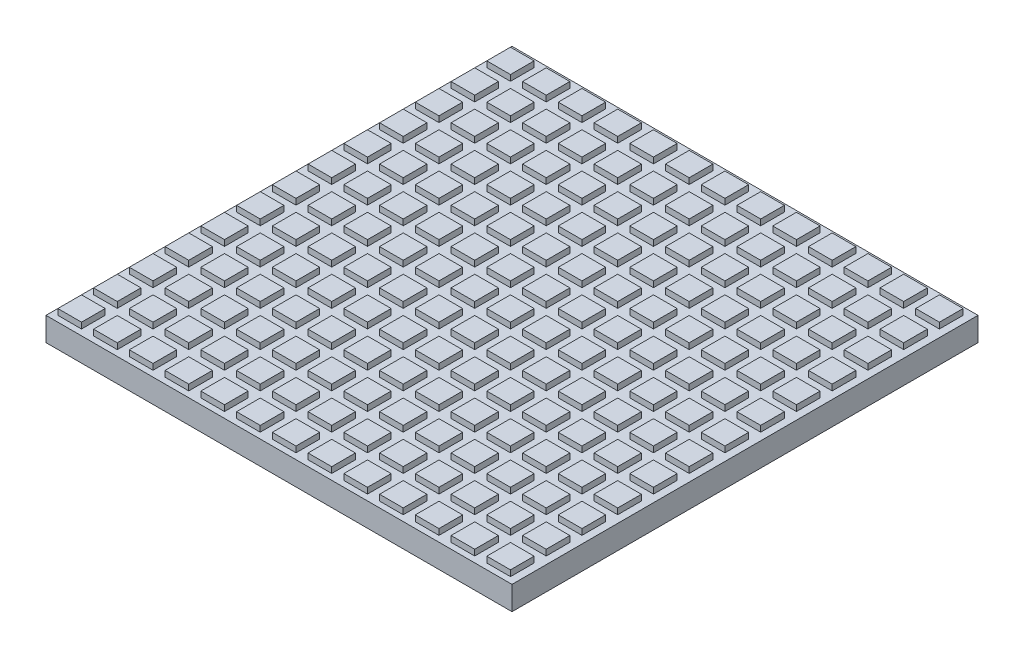
from build123d import *

# Parameters (mm, degrees)
SKETCH1_W           = 500
SKETCH1_H           = 500
BOSS_EXTRUDE1_DEPTH = 25.4
SKETCH2_W           = 25.4
SKETCH2_H           = 25.4
BOSS_EXTRUDE2_DEPTH = 6.35


with BuildPart() as part:
    # Sketch1 → Boss-Extrude1 (new body)
    with BuildSketch(Plane(origin=(0, 0, 0), x_dir=(1, 0, 0), z_dir=(0, 1, 0))):
        Rectangle(SKETCH1_W, SKETCH1_H)
    extrude(amount=BOSS_EXTRUDE1_DEPTH)

    # Sketch2 → Boss-Extrude2 (add)
    with BuildSketch(Plane(origin=(0, 25.4, 0), x_dir=(1, 0, 0), z_dir=(0, 1, 0))):
        with Locations((-230.95, -230.95)):
            Rectangle(SKETCH2_W, SKETCH2_H)
        with Locations((-192.596, -230.95)):
            Rectangle(SKETCH2_W, SKETCH2_H)
        with Locations((-154.242, -230.95)):
            Rectangle(SKETCH2_W, SKETCH2_H)
        with Locations((-115.888, -230.95)):
            Rectangle(SKETCH2_W, SKETCH2_H)
        with Locations((-77.534, -230.95)):
            Rectangle(SKETCH2_W, SKETCH2_H)
        with Locations((-39.18, -230.95)):
            Rectangle(SKETCH2_W, SKETCH2_H)
        with Locations((-0.826, -230.95)):
            Rectangle(SKETCH2_W, SKETCH2_H)
        with Locations((37.528, -230.95)):
            Rectangle(SKETCH2_W, SKETCH2_H)
        with Locations((75.882, -230.95)):
            Rectangle(SKETCH2_W, SKETCH2_H)
        with Locations((114.236, -230.95)):
            Rectangle(SKETCH2_W, SKETCH2_H)
        with Locations((152.59, -230.95)):
            Rectangle(SKETCH2_W, SKETCH2_H)
        with Locations((190.944, -230.95)):
            Rectangle(SKETCH2_W, SKETCH2_H)
        with Locations((229.298, -230.95)):
            Rectangle(SKETCH2_W, SKETCH2_H)
        with Locations((-192.596, -192.596)):
            Rectangle(SKETCH2_W, SKETCH2_H)
        with Locations((-154.242, -192.596)):
            Rectangle(SKETCH2_W, SKETCH2_H)
        with Locations((-115.888, -192.596)):
            Rectangle(SKETCH2_W, SKETCH2_H)
        with Locations((-77.534, -192.596)):
            Rectangle(SKETCH2_W, SKETCH2_H)
        with Locations((-39.18, -192.596)):
            Rectangle(SKETCH2_W, SKETCH2_H)
        with Locations((-0.826, -192.596)):
            Rectangle(SKETCH2_W, SKETCH2_H)
        with Locations((37.528, -192.596)):
            Rectangle(SKETCH2_W, SKETCH2_H)
        with Locations((75.882, -192.596)):
            Rectangle(SKETCH2_W, SKETCH2_H)
        with Locations((114.236, -192.596)):
            Rectangle(SKETCH2_W, SKETCH2_H)
        with Locations((152.59, -192.596)):
            Rectangle(SKETCH2_W, SKETCH2_H)
        with Locations((190.944, -192.596)):
            Rectangle(SKETCH2_W, SKETCH2_H)
        with Locations((229.298, -192.596)):
            Rectangle(SKETCH2_W, SKETCH2_H)
        with Locations((-192.596, -154.242)):
            Rectangle(SKETCH2_W, SKETCH2_H)
        with Locations((-154.242, -154.242)):
            Rectangle(SKETCH2_W, SKETCH2_H)
        with Locations((-115.888, -154.242)):
            Rectangle(SKETCH2_W, SKETCH2_H)
        with Locations((-77.534, -154.242)):
            Rectangle(SKETCH2_W, SKETCH2_H)
        with Locations((-39.18, -154.242)):
            Rectangle(SKETCH2_W, SKETCH2_H)
        with Locations((-0.826, -154.242)):
            Rectangle(SKETCH2_W, SKETCH2_H)
        with Locations((37.528, -154.242)):
            Rectangle(SKETCH2_W, SKETCH2_H)
        with Locations((75.882, -154.242)):
            Rectangle(SKETCH2_W, SKETCH2_H)
        with Locations((114.236, -154.242)):
            Rectangle(SKETCH2_W, SKETCH2_H)
        with Locations((152.59, -154.242)):
            Rectangle(SKETCH2_W, SKETCH2_H)
        with Locations((190.944, -154.242)):
            Rectangle(SKETCH2_W, SKETCH2_H)
        with Locations((229.298, -154.242)):
            Rectangle(SKETCH2_W, SKETCH2_H)
        with Locations((-192.596, -115.888)):
            Rectangle(SKETCH2_W, SKETCH2_H)
        with Locations((-154.242, -115.888)):
            Rectangle(SKETCH2_W, SKETCH2_H)
        with Locations((-115.888, -115.888)):
            Rectangle(SKETCH2_W, SKETCH2_H)
        with Locations((-77.534, -115.888)):
            Rectangle(SKETCH2_W, SKETCH2_H)
        with Locations((-39.18, -115.888)):
            Rectangle(SKETCH2_W, SKETCH2_H)
        with Locations((-0.826, -115.888)):
            Rectangle(SKETCH2_W, SKETCH2_H)
        with Locations((37.528, -115.888)):
            Rectangle(SKETCH2_W, SKETCH2_H)
        with Locations((75.882, -115.888)):
            Rectangle(SKETCH2_W, SKETCH2_H)
        with Locations((114.236, -115.888)):
            Rectangle(SKETCH2_W, SKETCH2_H)
        with Locations((152.59, -115.888)):
            Rectangle(SKETCH2_W, SKETCH2_H)
        with Locations((190.944, -115.888)):
            Rectangle(SKETCH2_W, SKETCH2_H)
        with Locations((229.298, -115.888)):
            Rectangle(SKETCH2_W, SKETCH2_H)
        with Locations((-192.596, -77.534)):
            Rectangle(SKETCH2_W, SKETCH2_H)
        with Locations((-154.242, -77.534)):
            Rectangle(SKETCH2_W, SKETCH2_H)
        with Locations((-115.888, -77.534)):
            Rectangle(SKETCH2_W, SKETCH2_H)
        with Locations((-77.534, -77.534)):
            Rectangle(SKETCH2_W, SKETCH2_H)
        with Locations((-39.18, -77.534)):
            Rectangle(SKETCH2_W, SKETCH2_H)
        with Locations((-0.826, -77.534)):
            Rectangle(SKETCH2_W, SKETCH2_H)
        with Locations((37.528, -77.534)):
            Rectangle(SKETCH2_W, SKETCH2_H)
        with Locations((75.882, -77.534)):
            Rectangle(SKETCH2_W, SKETCH2_H)
        with Locations((114.236, -77.534)):
            Rectangle(SKETCH2_W, SKETCH2_H)
        with Locations((152.59, -77.534)):
            Rectangle(SKETCH2_W, SKETCH2_H)
        with Locations((190.944, -77.534)):
            Rectangle(SKETCH2_W, SKETCH2_H)
        with Locations((229.298, -77.534)):
            Rectangle(SKETCH2_W, SKETCH2_H)
        with Locations((-192.596, -39.18)):
            Rectangle(SKETCH2_W, SKETCH2_H)
        with Locations((-154.242, -39.18)):
            Rectangle(SKETCH2_W, SKETCH2_H)
        with Locations((-115.888, -39.18)):
            Rectangle(SKETCH2_W, SKETCH2_H)
        with Locations((-77.534, -39.18)):
            Rectangle(SKETCH2_W, SKETCH2_H)
        with Locations((-39.18, -39.18)):
            Rectangle(SKETCH2_W, SKETCH2_H)
        with Locations((-0.826, -39.18)):
            Rectangle(SKETCH2_W, SKETCH2_H)
        with Locations((37.528, -39.18)):
            Rectangle(SKETCH2_W, SKETCH2_H)
        with Locations((75.882, -39.18)):
            Rectangle(SKETCH2_W, SKETCH2_H)
        with Locations((114.236, -39.18)):
            Rectangle(SKETCH2_W, SKETCH2_H)
        with Locations((152.59, -39.18)):
            Rectangle(SKETCH2_W, SKETCH2_H)
        with Locations((190.944, -39.18)):
            Rectangle(SKETCH2_W, SKETCH2_H)
        with Locations((229.298, -39.18)):
            Rectangle(SKETCH2_W, SKETCH2_H)
        with Locations((-192.596, -0.826)):
            Rectangle(SKETCH2_W, SKETCH2_H)
        with Locations((-154.242, -0.826)):
            Rectangle(SKETCH2_W, SKETCH2_H)
        with Locations((-115.888, -0.826)):
            Rectangle(SKETCH2_W, SKETCH2_H)
        with Locations((-77.534, -0.826)):
            Rectangle(SKETCH2_W, SKETCH2_H)
        with Locations((-39.18, -0.826)):
            Rectangle(SKETCH2_W, SKETCH2_H)
        with Locations((-0.826, -0.826)):
            Rectangle(SKETCH2_W, SKETCH2_H)
        with Locations((37.528, -0.826)):
            Rectangle(SKETCH2_W, SKETCH2_H)
        with Locations((75.882, -0.826)):
            Rectangle(SKETCH2_W, SKETCH2_H)
        with Locations((114.236, -0.826)):
            Rectangle(SKETCH2_W, SKETCH2_H)
        with Locations((152.59, -0.826)):
            Rectangle(SKETCH2_W, SKETCH2_H)
        with Locations((190.944, -0.826)):
            Rectangle(SKETCH2_W, SKETCH2_H)
        with Locations((229.298, -0.826)):
            Rectangle(SKETCH2_W, SKETCH2_H)
        with Locations((-192.596, 37.528)):
            Rectangle(SKETCH2_W, SKETCH2_H)
        with Locations((-154.242, 37.528)):
            Rectangle(SKETCH2_W, SKETCH2_H)
        with Locations((-115.888, 37.528)):
            Rectangle(SKETCH2_W, SKETCH2_H)
        with Locations((-77.534, 37.528)):
            Rectangle(SKETCH2_W, SKETCH2_H)
        with Locations((-39.18, 37.528)):
            Rectangle(SKETCH2_W, SKETCH2_H)
        with Locations((-0.826, 37.528)):
            Rectangle(SKETCH2_W, SKETCH2_H)
        with Locations((37.528, 37.528)):
            Rectangle(SKETCH2_W, SKETCH2_H)
        with Locations((75.882, 37.528)):
            Rectangle(SKETCH2_W, SKETCH2_H)
        with Locations((114.236, 37.528)):
            Rectangle(SKETCH2_W, SKETCH2_H)
        with Locations((152.59, 37.528)):
            Rectangle(SKETCH2_W, SKETCH2_H)
        with Locations((190.944, 37.528)):
            Rectangle(SKETCH2_W, SKETCH2_H)
        with Locations((229.298, 37.528)):
            Rectangle(SKETCH2_W, SKETCH2_H)
        with Locations((-192.596, 75.882)):
            Rectangle(SKETCH2_W, SKETCH2_H)
        with Locations((-154.242, 75.882)):
            Rectangle(SKETCH2_W, SKETCH2_H)
        with Locations((-115.888, 75.882)):
            Rectangle(SKETCH2_W, SKETCH2_H)
        with Locations((-77.534, 75.882)):
            Rectangle(SKETCH2_W, SKETCH2_H)
        with Locations((-39.18, 75.882)):
            Rectangle(SKETCH2_W, SKETCH2_H)
        with Locations((-0.826, 75.882)):
            Rectangle(SKETCH2_W, SKETCH2_H)
        with Locations((37.528, 75.882)):
            Rectangle(SKETCH2_W, SKETCH2_H)
        with Locations((75.882, 75.882)):
            Rectangle(SKETCH2_W, SKETCH2_H)
        with Locations((114.236, 75.882)):
            Rectangle(SKETCH2_W, SKETCH2_H)
        with Locations((152.59, 75.882)):
            Rectangle(SKETCH2_W, SKETCH2_H)
        with Locations((190.944, 75.882)):
            Rectangle(SKETCH2_W, SKETCH2_H)
        with Locations((229.298, 75.882)):
            Rectangle(SKETCH2_W, SKETCH2_H)
        with Locations((-192.596, 114.236)):
            Rectangle(SKETCH2_W, SKETCH2_H)
        with Locations((-154.242, 114.236)):
            Rectangle(SKETCH2_W, SKETCH2_H)
        with Locations((-115.888, 114.236)):
            Rectangle(SKETCH2_W, SKETCH2_H)
        with Locations((-77.534, 114.236)):
            Rectangle(SKETCH2_W, SKETCH2_H)
        with Locations((-39.18, 114.236)):
            Rectangle(SKETCH2_W, SKETCH2_H)
        with Locations((-0.826, 114.236)):
            Rectangle(SKETCH2_W, SKETCH2_H)
        with Locations((37.528, 114.236)):
            Rectangle(SKETCH2_W, SKETCH2_H)
        with Locations((75.882, 114.236)):
            Rectangle(SKETCH2_W, SKETCH2_H)
        with Locations((114.236, 114.236)):
            Rectangle(SKETCH2_W, SKETCH2_H)
        with Locations((152.59, 114.236)):
            Rectangle(SKETCH2_W, SKETCH2_H)
        with Locations((190.944, 114.236)):
            Rectangle(SKETCH2_W, SKETCH2_H)
        with Locations((229.298, 114.236)):
            Rectangle(SKETCH2_W, SKETCH2_H)
        with Locations((-192.596, 152.59)):
            Rectangle(SKETCH2_W, SKETCH2_H)
        with Locations((-154.242, 152.59)):
            Rectangle(SKETCH2_W, SKETCH2_H)
        with Locations((-115.888, 152.59)):
            Rectangle(SKETCH2_W, SKETCH2_H)
        with Locations((-77.534, 152.59)):
            Rectangle(SKETCH2_W, SKETCH2_H)
        with Locations((-39.18, 152.59)):
            Rectangle(SKETCH2_W, SKETCH2_H)
        with Locations((-0.826, 152.59)):
            Rectangle(SKETCH2_W, SKETCH2_H)
        with Locations((37.528, 152.59)):
            Rectangle(SKETCH2_W, SKETCH2_H)
        with Locations((75.882, 152.59)):
            Rectangle(SKETCH2_W, SKETCH2_H)
        with Locations((114.236, 152.59)):
            Rectangle(SKETCH2_W, SKETCH2_H)
        with Locations((152.59, 152.59)):
            Rectangle(SKETCH2_W, SKETCH2_H)
        with Locations((190.944, 152.59)):
            Rectangle(SKETCH2_W, SKETCH2_H)
        with Locations((229.298, 152.59)):
            Rectangle(SKETCH2_W, SKETCH2_H)
        with Locations((-192.596, 190.944)):
            Rectangle(SKETCH2_W, SKETCH2_H)
        with Locations((-154.242, 190.944)):
            Rectangle(SKETCH2_W, SKETCH2_H)
        with Locations((-115.888, 190.944)):
            Rectangle(SKETCH2_W, SKETCH2_H)
        with Locations((-77.534, 190.944)):
            Rectangle(SKETCH2_W, SKETCH2_H)
        with Locations((-39.18, 190.944)):
            Rectangle(SKETCH2_W, SKETCH2_H)
        with Locations((-0.826, 190.944)):
            Rectangle(SKETCH2_W, SKETCH2_H)
        with Locations((37.528, 190.944)):
            Rectangle(SKETCH2_W, SKETCH2_H)
        with Locations((75.882, 190.944)):
            Rectangle(SKETCH2_W, SKETCH2_H)
        with Locations((114.236, 190.944)):
            Rectangle(SKETCH2_W, SKETCH2_H)
        with Locations((152.59, 190.944)):
            Rectangle(SKETCH2_W, SKETCH2_H)
        with Locations((190.944, 190.944)):
            Rectangle(SKETCH2_W, SKETCH2_H)
        with Locations((229.298, 190.944)):
            Rectangle(SKETCH2_W, SKETCH2_H)
        with Locations((-192.596, 229.298)):
            Rectangle(SKETCH2_W, SKETCH2_H)
        with Locations((-154.242, 229.298)):
            Rectangle(SKETCH2_W, SKETCH2_H)
        with Locations((-115.888, 229.298)):
            Rectangle(SKETCH2_W, SKETCH2_H)
        with Locations((-77.534, 229.298)):
            Rectangle(SKETCH2_W, SKETCH2_H)
        with Locations((-39.18, 229.298)):
            Rectangle(SKETCH2_W, SKETCH2_H)
        with Locations((-0.826, 229.298)):
            Rectangle(SKETCH2_W, SKETCH2_H)
        with Locations((37.528, 229.298)):
            Rectangle(SKETCH2_W, SKETCH2_H)
        with Locations((75.882, 229.298)):
            Rectangle(SKETCH2_W, SKETCH2_H)
        with Locations((114.236, 229.298)):
            Rectangle(SKETCH2_W, SKETCH2_H)
        with Locations((152.59, 229.298)):
            Rectangle(SKETCH2_W, SKETCH2_H)
        with Locations((190.944, 229.298)):
            Rectangle(SKETCH2_W, SKETCH2_H)
        with Locations((229.298, 229.298)):
            Rectangle(SKETCH2_W, SKETCH2_H)
        with Locations((-230.95, -192.596)):
            Rectangle(SKETCH2_W, SKETCH2_H)
        with Locations((-230.95, -154.242)):
            Rectangle(SKETCH2_W, SKETCH2_H)
        with Locations((-230.95, -115.888)):
            Rectangle(SKETCH2_W, SKETCH2_H)
        with Locations((-230.95, -77.534)):
            Rectangle(SKETCH2_W, SKETCH2_H)
        with Locations((-230.95, -39.18)):
            Rectangle(SKETCH2_W, SKETCH2_H)
        with Locations((-230.95, -0.826)):
            Rectangle(SKETCH2_W, SKETCH2_H)
        with Locations((-230.95, 37.528)):
            Rectangle(SKETCH2_W, SKETCH2_H)
        with Locations((-230.95, 75.882)):
            Rectangle(SKETCH2_W, SKETCH2_H)
        with Locations((-230.95, 114.236)):
            Rectangle(SKETCH2_W, SKETCH2_H)
        with Locations((-230.95, 152.59)):
            Rectangle(SKETCH2_W, SKETCH2_H)
        with Locations((-230.95, 190.944)):
            Rectangle(SKETCH2_W, SKETCH2_H)
        with Locations((-230.95, 229.298)):
            Rectangle(SKETCH2_W, SKETCH2_H)
    extrude(amount=BOSS_EXTRUDE2_DEPTH)


solid = part.part
